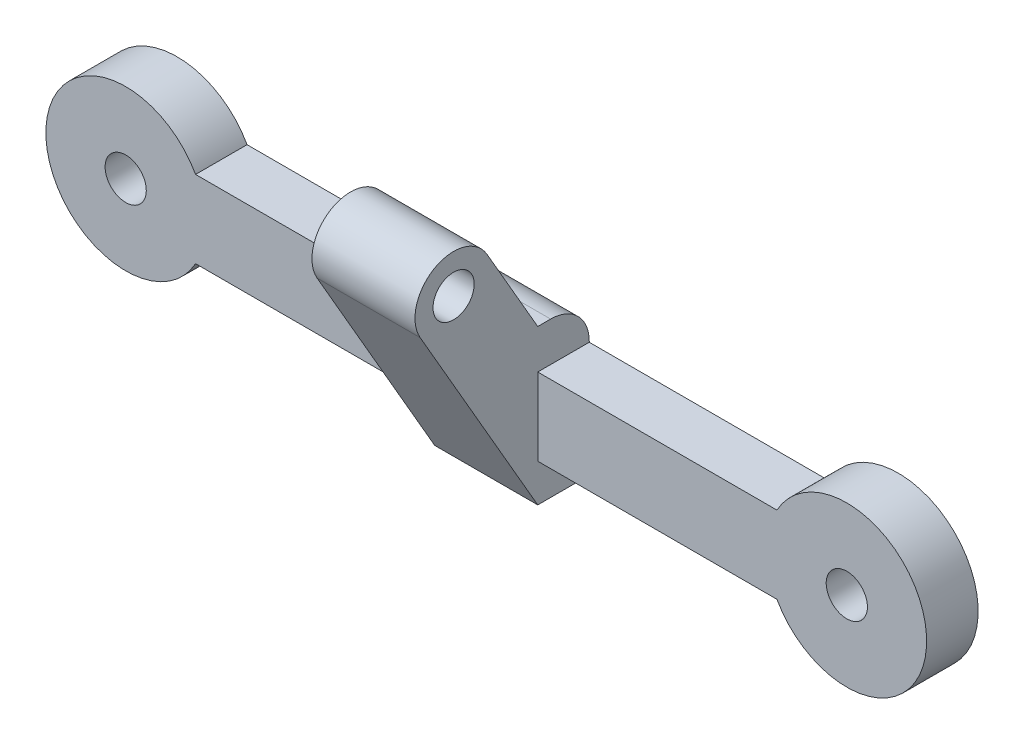
from build123d import *

# Parameters (mm, degrees)
CROQUIS1_R                   = 1.6
SALIENTE_EXTRUIR1_DEPTH      = 4
SALIENTE_EXTRUIR2_DEPTH      = 4
SALIENTE_EXTRUIR2_DEPTH_BACK = 4
CROQUIS2_R                   = 1.6
REDONDEO1_R                  = 3


with BuildPart() as part:
    # Croquis1 → Saliente-Extruir1 (new body)
    with BuildSketch(Plane.XY):
        with BuildLine():
            Line((5.425863987, -3), (50.574136013, -3))
            ThreePointArc((50.574136013, -3), (62.2, 0), (50.574136013, 3))
            Line((50.574136013, 3), (5.425863987, 3))
            ThreePointArc((5.425863987, 3), (-6.2, 0), (5.425863987, -3))
        make_face()
        Circle(CROQUIS1_R, mode=Mode.SUBTRACT)
        with Locations((56, 0)):
            Circle(CROQUIS1_R, mode=Mode.SUBTRACT)
    extrude(amount=SALIENTE_EXTRUIR1_DEPTH)

    # Croquis2 → Saliente-Extruir2 (add, two sides: drawn at the far end of the back side and taken through both)
    with BuildSketch(Plane(origin=(28, 0, 0), x_dir=(0, 0, -1), z_dir=(1, 0, 0)).offset(-SALIENTE_EXTRUIR2_DEPTH_BACK)):
        with BuildLine():
            Line((-4, -5.939790903), (-13.133231147, 9.879429481))
            ThreePointArc((-13.133231147, 9.879429481), (-12.035154935, 13.977505692), (-7.937078724, 12.879429481))
            Line((-7.937078724, 12.879429481), (-4, 6.060209097))
            Line((-4, 6.060209097), (0, 6.060209097))
            Line((0, 6.060209097), (0, -5.939790903))
            Line((0, -5.939790903), (-4, -5.939790903))
        make_face()
        with Locations((-10.535154935, 11.379429481)):
            Circle(CROQUIS2_R, mode=Mode.SUBTRACT)
    extrude(amount=SALIENTE_EXTRUIR2_DEPTH + SALIENTE_EXTRUIR2_DEPTH_BACK)

    # Redondeo1
    redondeo1_edges = [part.edges().sort_by_distance(p)[0] for p in [
        (28, 6.060209097, 0),
    ]]
    fillet(redondeo1_edges, radius=REDONDEO1_R)


solid = part.part
